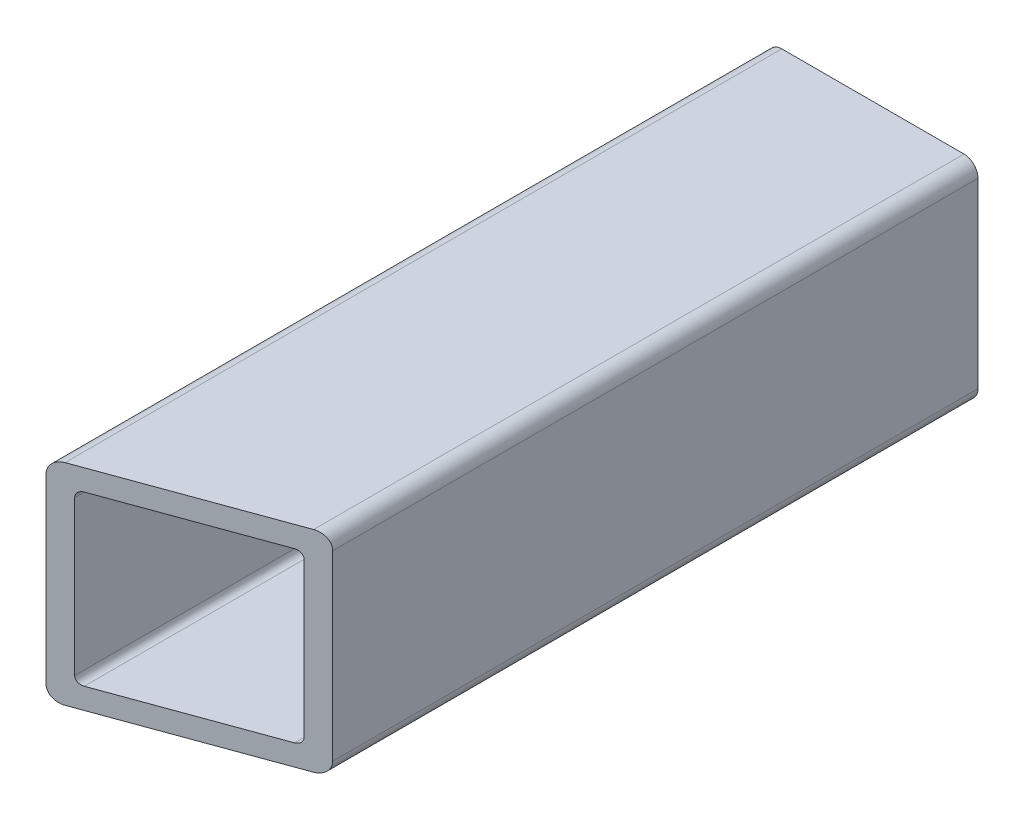
from build123d import *

# Parameters (mm, degrees)
DODANIE_WYCI_GNI_CIE1_DEPTH = 103
WYTNIJ_WYCI_GNI_CIE1_DEPTH  = 70


with BuildPart() as part:
    # Szkic1 → Dodanie-wyciągnięcie1 (new body)
    with BuildSketch(Plane.XY):
        with BuildLine():
            Line((-13, -3), (13, -3))
            ThreePointArc((13, -3), (14.414213562, -2.414213562), (15, -1))
            Line((15, -1), (15, 25))
            ThreePointArc((15, 25), (14.414213562, 26.414213562), (13, 27))
            Line((13, 27), (-13, 27))
            ThreePointArc((-13, 27), (-14.414213562, 26.414213562), (-15, 25))
            Line((-15, 25), (-15, -1))
            ThreePointArc((-15, -1), (-14.414213562, -2.414213562), (-13, -3))
        make_face()
        with BuildLine():
            Line((-11, 0), (11, 0))
            ThreePointArc((11, 0), (11.707106781, 0.292893219), (12, 1))
            Line((12, 1), (12, 23))
            ThreePointArc((12, 23), (11.707106781, 23.707106781), (11, 24))
            Line((11, 24), (-11, 24))
            ThreePointArc((-11, 24), (-11.707106781, 23.707106781), (-12, 23))
            Line((-12, 23), (-12, 1))
            ThreePointArc((-12, 1), (-11.707106781, 0.292893219), (-11, 0))
        make_face(mode=Mode.SUBTRACT)
    extrude(amount=DODANIE_WYCI_GNI_CIE1_DEPTH)

    # Szkic2 → Wytnij-wyciągnięcie1 (cut)
    with BuildSketch(Plane.XZ.offset(3)):
        Polygon((-15, 103), (66.156264481, 73.461535405), (66.156264481, 103), align=None)
    extrude(amount=-WYTNIJ_WYCI_GNI_CIE1_DEPTH, mode=Mode.SUBTRACT)


solid = part.part
